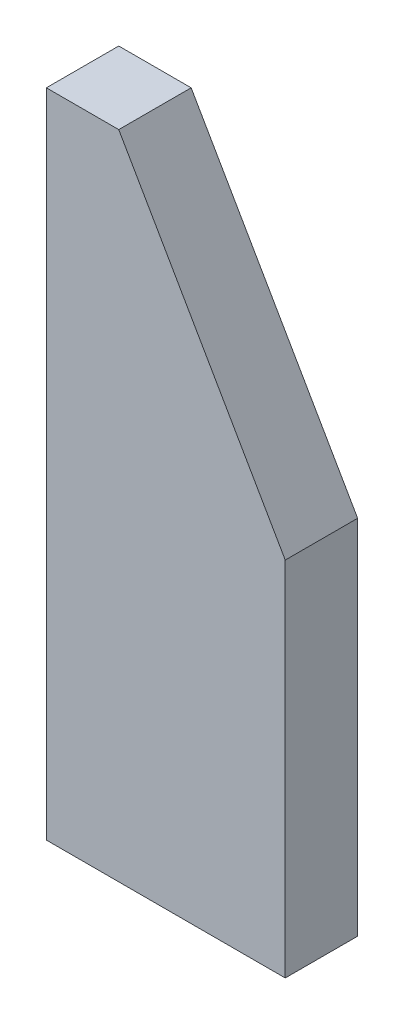
from build123d import *

# Parameters (mm, degrees)
EXTRUDE1_DEPTH = 20


with BuildPart() as part:
    # Sketch1 → Extrude1 (new body)
    with BuildSketch(Plane.XY):
        Polygon((0, 0), (66, 0), (66, 100), (20, 180), (0, 180), align=None)
    extrude(amount=EXTRUDE1_DEPTH)


solid = part.part
